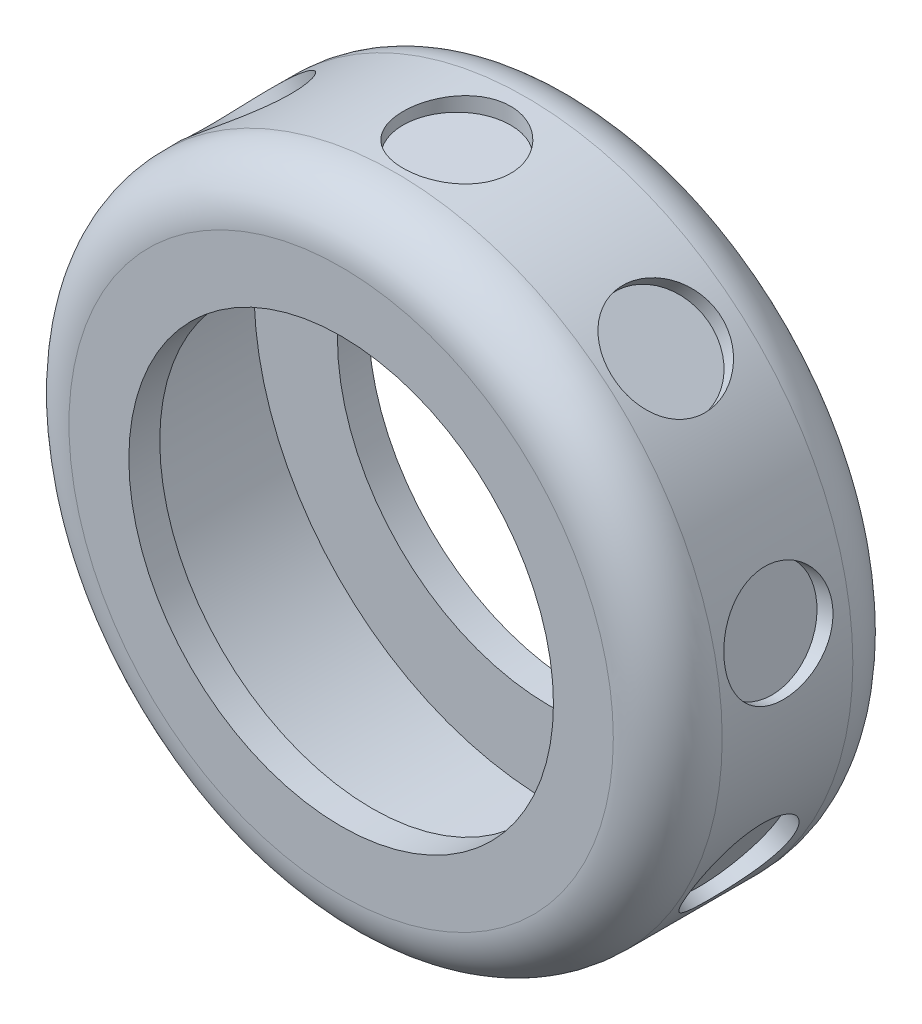
from build123d import *

# Parameters (mm, degrees)
SKETCH5_R           = 30
BOSS_EXTRUDE2_DEPTH = 22
SKETCH6_R           = 19.5
CUT_EXTRUDE3_DEPTH  = 22
SHELL4_T            = -2.84
FILLET2_R           = 5
SKETCH7_R           = 4.938582487
CUT_EXTRUDE4_DEPTH  = 22
CIRPATTERN1_COUNT   = 9


with BuildPart() as part:
    # Sketch5 → Boss-Extrude2 (new body)
    with BuildSketch(Plane.XY):
        Circle(SKETCH5_R)
    extrude(amount=BOSS_EXTRUDE2_DEPTH)

    # Sketch6 → Cut-Extrude3 (cut)
    with BuildSketch(Plane.XY):
        Circle(SKETCH6_R)
    extrude(amount=CUT_EXTRUDE3_DEPTH, mode=Mode.SUBTRACT)

    # Shell4
    shell4_openings = [part.faces().sort_by_distance(p)[0] for p in [
        (-19.5, 0, 11),
    ]]
    offset(amount=SHELL4_T, openings=shell4_openings, kind=Kind.INTERSECTION)

    # Fillet2
    fillet2_edges = [part.edges().sort_by_distance(p)[0] for p in [
        (-30, 0, 0),
        (-30, 0, 22),
    ]]
    fillet(fillet2_edges, radius=FILLET2_R)

    # Sketch7 → Cut-Extrude4 (cut)
    with BuildSketch(Plane(origin=(0, 28.5, 0), x_dir=(1, 0, 0), z_dir=(0, 1, 0))):
        with Locations((0, -11.372504627)):
            Circle(SKETCH7_R)
    cut_extrude4 = extrude(amount=CUT_EXTRUDE4_DEPTH, mode=Mode.SUBTRACT)

    # CirPattern1: Cut-Extrude4 ×9 about axis
    cirpattern1_axis = Axis((0, 0, 23.1), (0, 0, -1))
    for i in range(1, CIRPATTERN1_COUNT):
        add(cut_extrude4.rotate(cirpattern1_axis, i * 360 / CIRPATTERN1_COUNT), mode=Mode.SUBTRACT)


solid = part.part
